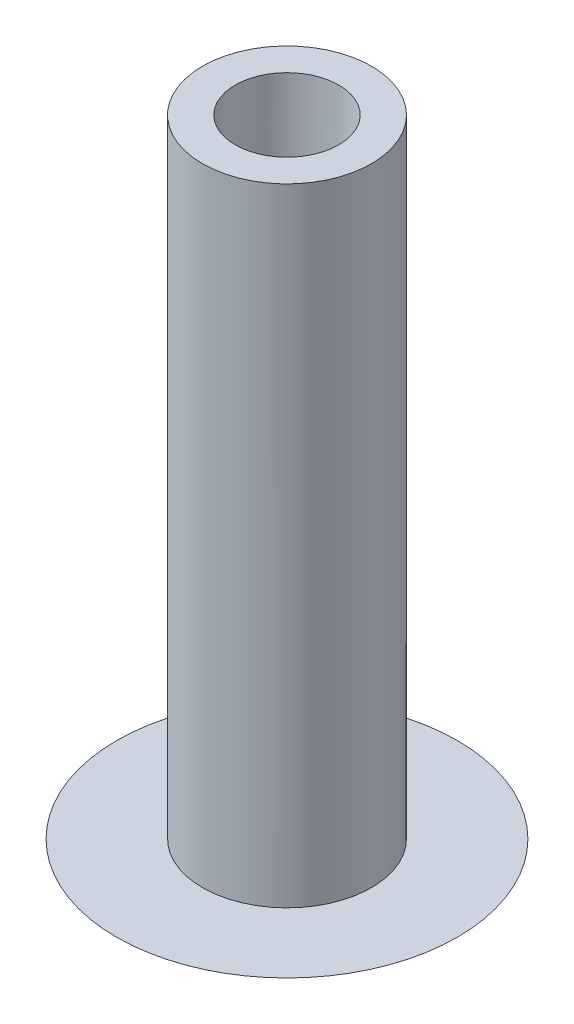
from build123d import *

# Parameters (mm, degrees)
SKETCH1_R           = 3.937
SKETCH1_R_2         = 2.413
BOSS_EXTRUDE1_DEPTH = 29.21


with BuildPart() as part:
    # Sketch1 → Boss-Extrude1 (new body)
    with BuildSketch(Plane(origin=(0, 0, 0), x_dir=(1, 0, 0), z_dir=(0, 1, 0))):
        Circle(SKETCH1_R)
        Circle(SKETCH1_R_2, mode=Mode.SUBTRACT)
    extrude(amount=BOSS_EXTRUDE1_DEPTH)

    # Sketch2 one side → Revolve1 (revolve)
    with BuildSketch(Plane.XY):
        with BuildLine():
            ThreePointArc((0, -2.54), (4.166998508, -1.889526586), (7.9375, 0))
            Line((7.9375, 0), (0, 0))
            Line((0, 0), (0, -2.54))
        make_face()
    revolve(axis=Axis((0, 0, 0), (0, -1, 0)))

    # Sketch3 → Revolve2 (revolve)
    with BuildSketch(Plane.XY):
        Polygon((2.413, 16.51), (2.413, 29.21), (2.032, 16.51), align=None)
        Polygon((2.413, 0), (2.413, 16.51), (2.032, 16.51), (1.5367, 0), align=None)
    revolve(axis=Axis((0, 0, 0), (0, 1, 0)))


solid = part.part
